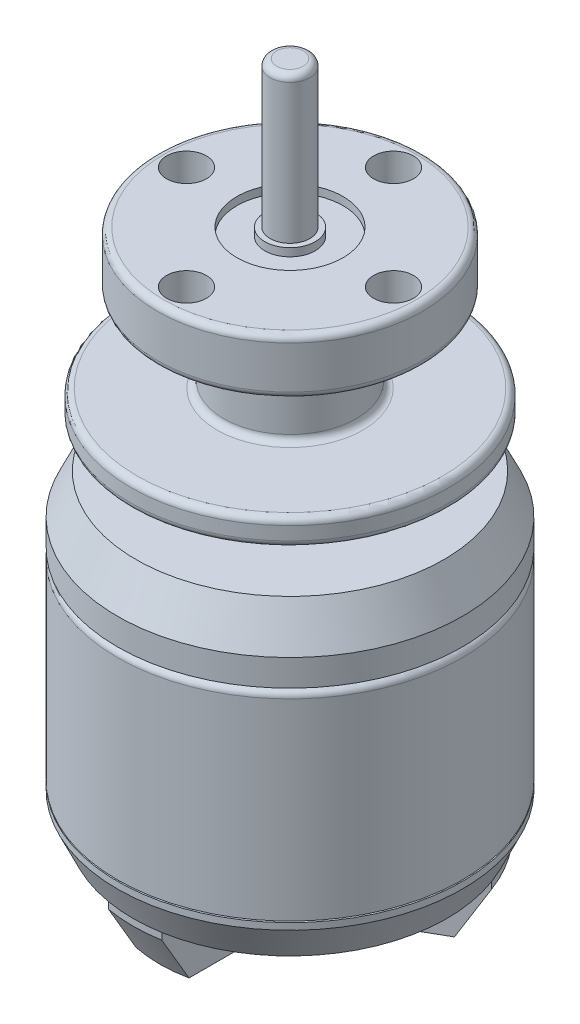
from build123d import *
from OCP.BRepFilletAPI import BRepFilletAPI_MakeChamfer

# Parameters (mm, degrees)
SKETCH1_R            = 13
BOSS_EXTRUDE1_DEPTH  = 15
SKETCH2_R            = 7
BOSS_EXTRUDE2_DEPTH  = 0.2
SKETCH4_R            = 13.000000000000004
BOSS_EXTRUDE3_DEPTH  = 5
SKETCH5_R            = 5
BOSS_EXTRUDE4_DEPTH  = 3.4
SKETCH6_R            = 12
BOSS_EXTRUDE5_DEPTH  = 2
SKETCH7_R            = 5
BOSS_EXTRUDE6_DEPTH  = 6.3
SKETCH8_R            = 10
BOSS_EXTRUDE7_DEPTH  = 4.2
CHAMFER1_SIZE        = 3
CHAMFER1_SIZE2       = 1.3989229744649996
FILLET1_R            = 0.5
SKETCH9_R            = 8.463574214087313
BOSS_EXTRUDE8_DEPTH  = 0.1
BOSS_EXTRUDE9_START  = 3
SKETCH10_R           = 13.000000000000004
BOSS_EXTRUDE9_DEPTH  = 3
CHAMFER2_SIZE        = 2.5
CHAMFER2_SIZE2       = 1.1657691453874992
BOSS_EXTRUDE10_START = 4
BOSS_EXTRUDE10_DEPTH = 4
CHAMFER3_SIZE        = 3.5
CHAMFER3_SIZE2       = 2.0207259421636956
SKETCH13_R           = 10.77059477245057
CUT_EXTRUDE1_DEPTH   = 4
SKETCH14_R           = 4.5
BOSS_EXTRUDE11_DEPTH = 1
FILLET2_R            = 0.7
FILLET3_R            = 2
SKETCH15_R           = 1.5000000000000002
CUT_EXTRUDE2_DEPTH   = 4
CIRPATTERN1_COUNT    = 3
SKETCH16_R           = 1.7
SKETCH16_R_2         = 1.5
CUT_EXTRUDE3_DEPTH   = 2
FILLET4_R            = 0.3
SKETCH17_R           = 4
SKETCH17_R_2         = 1.9
CUT_EXTRUDE4_DEPTH   = 0.6
SKETCH18_R           = 1.5
BOSS_EXTRUDE12_DEPTH = 11
FILLET5_R            = 0.5
SKETCH19_R           = 1.4999999999999998
CUT_EXTRUDE5_DEPTH   = 5
CIRPATTERN2_COUNT    = 4


with BuildPart() as part:
    # Sketch1 → Boss-Extrude1 (new body)
    with BuildSketch(Plane(origin=(0, 0, 0), x_dir=(1, 0, 0), z_dir=(0, 1, 0))):
        with Locations(Location((0, 0, 0), (0, 0, 270))):
            Circle(SKETCH1_R)
    extrude(amount=BOSS_EXTRUDE1_DEPTH)

    # Sketch2 → Boss-Extrude2 (add)
    with BuildSketch(Plane(origin=(0, 15, 0), x_dir=(1, 0, 0), z_dir=(0, 1, 0))):
        with Locations(Location((0, 0, 0), (0, 0, 270))):
            Circle(SKETCH2_R)
    extrude(amount=BOSS_EXTRUDE2_DEPTH)

    # Sketch4 → Boss-Extrude3 (add)
    with BuildSketch(Plane(origin=(0, 15.2, 0), x_dir=(1, 0, 0), z_dir=(0, 1, 0))):
        with Locations(Location((0, 0, 0), (0, 0, 270))):
            Circle(SKETCH4_R)
    extrude(amount=BOSS_EXTRUDE3_DEPTH)

    # Sketch5 → Boss-Extrude4 (add)
    with BuildSketch(Plane(origin=(0, 20.2, 0), x_dir=(1, 0, 0), z_dir=(0, 1, 0))):
        with Locations(Location((0, 0, 0), (0, 0, 270))):
            Circle(SKETCH5_R)
    extrude(amount=BOSS_EXTRUDE4_DEPTH)

    # Sketch6 → Boss-Extrude5 (add)
    with BuildSketch(Plane(origin=(0, 23.599999999999998, 0), x_dir=(1, 0, 0), z_dir=(0, 1, 0))):
        with Locations(Location((0, 0, 0), (0, 0, 270))):
            Circle(SKETCH6_R)
    extrude(amount=BOSS_EXTRUDE5_DEPTH)

    # Sketch7 → Boss-Extrude6 (add)
    with BuildSketch(Plane(origin=(0, 25.599999999999998, 0), x_dir=(1, 0, 0), z_dir=(0, 1, 0))):
        with Locations(Location((0, 0, 0), (0, 0, 270))):
            Circle(SKETCH7_R)
    extrude(amount=BOSS_EXTRUDE6_DEPTH)

    # Sketch8 → Boss-Extrude7 (add)
    with BuildSketch(Plane(origin=(0, 31.9, 0), x_dir=(1, 0, 0), z_dir=(0, 1, 0))):
        with Locations(Location((0, 0, 0), (0, 0, 270))):
            Circle(SKETCH8_R)
    extrude(amount=BOSS_EXTRUDE7_DEPTH)

    # Chamfer1
    chamfer1_edges = [part.edges().sort_by_distance(p)[0] for p in [
        (3.98e-15, 20.2, -13.000000000000004),
    ]]
    chamfer1_side = [part.faces().sort_by_distance(p)[0] for p in [
        (3.98e-15, 17.7, -13.000000000000004),
    ]]
    chamfer(chamfer1_edges, length=CHAMFER1_SIZE, length2=CHAMFER1_SIZE2, reference=chamfer1_side[0])

    # Fillet1
    fillet1_edges = [part.edges().sort_by_distance(p)[0] for p in [
        (1.53e-15, 20.2, -5),
        (1.53e-15, 23.599999999999998, -5),
        (3.67e-15, 23.599999999999998, -12),
        (3.67e-15, 25.599999999999998, -12),
        (1.53e-15, 25.599999999999998, -5),
        (1.53e-15, 31.9, -5),
        (3.06e-15, 31.9, -10),
        (3.06e-15, 36.1, -10),
        (-1.79e-15, 15, -13),
    ]]
    fillet(fillet1_edges, radius=FILLET1_R)

    # Sketch9 → Boss-Extrude8 (add)
    with BuildSketch(Plane.XZ):
        with Locations(Location((0, 0, 0), (0, 0, 270))):
            Circle(SKETCH9_R)
    extrude(amount=BOSS_EXTRUDE8_DEPTH)

    # Sketch10 → Boss-Extrude9 (add)
    with BuildSketch(Plane.XZ.offset(0.1).offset(BOSS_EXTRUDE9_START)):
        with Locations(Location((0, 0, 0), (0, 0, 90))):
            Circle(SKETCH10_R)
    extrude(amount=-BOSS_EXTRUDE9_DEPTH)

    # Chamfer2
    chamfer2_edges = [part.edges().sort_by_distance(p)[0] for p in [
        (-2.39e-15, -3.1, -13.000000000000004),
    ]]
    chamfer2_side = [part.faces().sort_by_distance(p)[0] for p in [
        (-2.39e-15, -1.6, -13.000000000000004),
    ]]
    chamfer(chamfer2_edges, length=CHAMFER2_SIZE, length2=CHAMFER2_SIZE2, reference=chamfer2_side[0])

    # Sketch12 → Boss-Extrude10 (add)
    with BuildSketch(Plane.XZ.offset(3.1).offset(BOSS_EXTRUDE10_START)):
        with BuildLine():
            Line((-4.968626966596926, -0.5592370399090334), (-11.10132491013915, -4.099951848471753))
            ThreePointArc((-11.1013249101391, -4.099951848471809), (-10.713631015383742, -5.026642058717716), (-10.248744788504228, -5.917115021728898))
            ThreePointArc((-10.248744788504228, -5.917115021728898), (-9.710015493984855, -6.764955212478231), (-9.101324910139237, -7.564053463609399))
            Line((-9.101324910139185, -7.56405346360953), (-2.9686269665968643, -4.023338655046755))
            ThreePointArc((-2.96862696659685, -4.023338655046824), (-4.330127018922175, -2.5000000000000315), (-4.968626966596883, -0.5592370399090708))
        make_face()
        with BuildLine():
            Line((-2.0000000000000036, 1.1547005383792586), (-4.968626966596926, -0.5592370399090334))
            ThreePointArc((-4.968626966596883, -0.5592370399090708), (-4.330127018922175, -2.5000000000000315), (-2.96862696659685, -4.023338655046824))
            Line((-2.9686269665968643, -4.023338655046755), (-3.55e-15, -2.3094010767584994))
            Line((-5.33e-15, -2.3094010767585016), (-1.000000000000002, -1.7320508075688765))
            Line((-1.000000000000002, -1.7320508075688765), (4.4e-16, 2.2e-16))
            Line((0, 2.3e-16), (-2, -1e-17))
            Line((-2, -1e-17), (-2, 1.15470053837926))
        make_face()
        with BuildLine():
            Line((-3.55e-15, -2.3094010767584994), (-2.9686269665968643, -4.023338655046755))
            ThreePointArc((-2.96862696659685, -4.023338655046824), (-1.868e-14, -5), (2.96862696659682, -4.023338655046846))
            Line((2.968626966596837, -4.023338655046775), (-5.33e-15, -2.3094010767585016))
        make_face()
        with BuildLine():
            Line((0.9999999999999911, -1.7320508075688847), (-3.55e-15, -2.3094010767584994))
            Line((-5.33e-15, -2.3094010767585016), (2.968626966596837, -4.023338655046775))
            ThreePointArc((2.96862696659682, -4.023338655046846), (4.330127018922203, -2.499999999999983), (4.968626966596899, -0.559237039908927))
            Line((4.968626966596811, -0.5592370399090061), (2.0000000000000027, 1.1547005383792481))
            Line((2.000000000000002, 1.1547005383792481), (2.0000000000000027, 4.8e-16))
            Line((2.0000000000000027, 4.8e-16), (0, 2.3e-16))
            Line((2.2e-16, -2.2e-16), (0.9999999999999907, -1.7320508075688847))
        make_face()
        with BuildLine():
            Line((2.968626966596837, -4.023338655046775), (9.10132491013913, -7.564053463609591))
            ThreePointArc((9.101324910139173, -7.564053463609475), (9.710015458843332, -6.76495526291829), (10.248744727029683, -5.917115128205941))
            ThreePointArc((10.248744727029683, -5.917115128205941), (10.713630989272133, -5.026642114371199), (11.101324910139066, -4.0999518484719015))
            Line((11.101324910139121, -4.099951848471832), (4.968626966596811, -0.5592370399090061))
            ThreePointArc((4.968626966596899, -0.559237039908927), (4.330127018922203, -2.499999999999983), (2.96862696659682, -4.023338655046846))
        make_face()
        Polygon((-1.000000000000002, -1.7320508075688765), (-5.33e-15, -2.3094010767585016), (0.9999999999999911, -1.7320508075688847), (2.2e-16, -2.2e-16), align=None)
        Polygon((1.000000000000002, 1.7320508075688756), (4.4e-16, 2.2e-16), (2.0000000000000027, 4.8e-16), (2.000000000000002, 1.1547005383792481), align=None)
        with BuildLine():
            ThreePointArc((5, 0), (4.183300132670404, 2.738612787525792), (2.0000000000000853, 4.5825756949558025))
            Line((2.0000000000000018, 4.582575694955776), (2.000000000000002, 1.1547005383792481))
            Line((2.0000000000000027, 1.1547005383792481), (4.968626966596811, -0.5592370399090061))
            ThreePointArc((4.968626966596899, -0.559237039908927), (4.992150580310278, -0.28005817879104034), (5, -1.22e-15))
        make_face()
        with BuildLine():
            Line((-2, 4.582575694955866), (-2, 1.15470053837926))
            Line((-2.0000000000000036, 1.1547005383792586), (-0.9999999999999911, 1.7320508075688839))
            Line((-0.9999999999999902, 1.7320508075688843), (2.2e-16, -2.2e-16))
            Line((4.4e-16, 2.2e-16), (1.000000000000002, 1.7320508075688756))
            Line((1.000000000000002, 1.7320508075688756), (2.0000000000000027, 1.1547005383792481))
            Line((2.000000000000002, 1.1547005383792481), (2.0000000000000018, 4.582575694955776))
            ThreePointArc((2.0000000000000853, 4.5825756949558025), (6.47e-14, 5), (-1.9999999999999662, 4.582575694955855))
        make_face()
        with BuildLine():
            ThreePointArc((-1.9999999999999662, 4.582575694955855), (-4.330127018922191, 2.500000000000004), (-4.968626966596883, -0.5592370399090708))
            Line((-4.968626966596926, -0.5592370399090334), (-2.0000000000000036, 1.1547005383792586))
            Line((-2, 1.15470053837926), (-2, 4.582575694955866))
        make_face()
        with BuildLine():
            ThreePointArc((5.853e-14, 11.834230854612493), (-1.0036155557942605, 11.791597675312286), (-1.9999999999997802, 11.664005312081404))
            Line((-2, 11.66400531208144), (-2, 4.582575694955866))
            ThreePointArc((-1.9999999999999662, 4.582575694955855), (6.47e-14, 5), (2.0000000000000853, 4.5825756949558025))
            Line((2.0000000000000018, 4.582575694955776), (2, 11.664005312081269))
            ThreePointArc((2.0000000000002918, 11.664005312081317), (1.0036155557945787, 11.791597675312259), (5.853e-14, 11.834230854612493))
        make_face()
        Polygon((-0.9999999999999911, 1.7320508075688839), (-2.0000000000000036, 1.1547005383792586), (-2, -1e-17), (0, 2.3e-16), align=None)
    extrude(amount=-BOSS_EXTRUDE10_DEPTH)

    # Chamfer3: one chamfer whose edges measure the first distance from different faces: ONE call of the kernel's chamfer builder (chamfer() names one face for all edges)
    chamfer3_edges_1 = [part.edges().sort_by_distance(p)[0] for p in [
        (10.248744554344045, -7.1, -5.917115427306248),
    ]]
    chamfer3_side_1 = [part.faces().sort_by_distance(p)[0] for p in [
        (10.248744554344047, -5.1, -5.917115427306248),
    ]]
    chamfer3_edges_2 = [part.edges().sort_by_distance(p)[0] for p in [
        (1.3683e-13, -7.1, 11.834230854612489),
    ]]
    chamfer3_side_2 = [part.faces().sort_by_distance(p)[0] for p in [
        (2.936e-13, -5.1, 11.834230854612489),
    ]]
    chamfer3_edges_3 = [part.edges().sort_by_distance(p)[0] for p in [
        (-10.24874455434409, -7.1, -5.917115427306171),
    ]]
    chamfer3_side_3 = [part.faces().sort_by_distance(p)[0] for p in [
        (-10.24874455434409, -5.1, -5.9171154273061735),
    ]]
    chamfer3 = BRepFilletAPI_MakeChamfer(part.part.solid().wrapped)
    for e in chamfer3_edges_1:
        chamfer3.Add(CHAMFER3_SIZE, CHAMFER3_SIZE2, e.wrapped, chamfer3_side_1[0].wrapped)  # the first distance lies on this face
    for e in chamfer3_edges_2:
        chamfer3.Add(CHAMFER3_SIZE, CHAMFER3_SIZE2, e.wrapped, chamfer3_side_2[0].wrapped)  # the first distance lies on this face
    for e in chamfer3_edges_3:
        chamfer3.Add(CHAMFER3_SIZE, CHAMFER3_SIZE2, e.wrapped, chamfer3_side_3[0].wrapped)  # the first distance lies on this face
    add(Compound.cast(chamfer3.Shape()), mode=Mode.REPLACE)

    # Sketch13 → Cut-Extrude1 (cut)
    with BuildSketch(Plane.XZ.offset(3.1)):
        with Locations(Location((0, 0, 0), (0, 0, 270))):
            Circle(SKETCH13_R)
    extrude(amount=-CUT_EXTRUDE1_DEPTH, mode=Mode.SUBTRACT)


with BuildPart() as cut_extrude1_piece_1:
    # of the separate pieces the step leaves, piece 1, a body of its own (cut_extrude1_pieces)
    add(part.part.solids().sort_by_distance((0, 0, 13))[0])

    # Sketch17 → Cut-Extrude4 (cut)
    with BuildSketch(Plane(origin=(0, 36.1, 0), x_dir=(1, 0, 0), z_dir=(0, 1, 0))):
        with Locations(Location((0, 0, 0), (0, 0, 270))):
            Circle(SKETCH17_R)
        with Locations(Location((0, 0, 0), (0, 0, 270))):
            Circle(SKETCH17_R_2, mode=Mode.SUBTRACT)
    extrude(amount=-CUT_EXTRUDE4_DEPTH, mode=Mode.SUBTRACT)

    # Sketch18 → Boss-Extrude12 (add)
    with BuildSketch(Plane(origin=(0, 36.1, 0), x_dir=(1, 0, 0), z_dir=(0, 1, 0))):
        with Locations(Location((0, 0, 0), (0, 0, 270))):
            Circle(SKETCH18_R)
    extrude(amount=BOSS_EXTRUDE12_DEPTH)

    # Fillet5
    fillet5_edges = [cut_extrude1_piece_1.edges().sort_by_distance(p)[0] for p in [
        (4.6e-16, 47.1, -1.5),
    ]]
    fillet(fillet5_edges, radius=FILLET5_R)

    # Sketch19 → Cut-Extrude5 (cut)
    with BuildSketch(Plane(origin=(0, 36.1, 0), x_dir=(1, 0, 0), z_dir=(0, 1, 0))):
        with Locations(Location((0, 7.8, 0), (0, 0, 270))):
            Circle(SKETCH19_R)
    cut_extrude5 = extrude(amount=-CUT_EXTRUDE5_DEPTH, mode=Mode.SUBTRACT)

    # CirPattern2: Cut-Extrude5 ×4 about axis
    cirpattern2_axis = Axis((-1.362e-14, 0, 0), (0, 1, 0))
    for i in range(1, CIRPATTERN2_COUNT):
        add(cut_extrude5.rotate(cirpattern2_axis, i * 360 / CIRPATTERN2_COUNT), mode=Mode.SUBTRACT)


with BuildPart() as cut_extrude1_piece_2:
    # of the separate pieces the step leaves, piece 2, a body of its own (cut_extrude1_pieces)
    add(part.part.solids().sort_by_distance((2, -3.6, 11.664005312))[0])

    # Sketch14 → Boss-Extrude11 (add)
    with BuildSketch(Plane.XZ.offset(7.1000000000000005)):
        with Locations(Location((0, 0, 0), (0, 0, 270))):
            Circle(SKETCH14_R)
    extrude(amount=BOSS_EXTRUDE11_DEPTH)

    # Fillet2
    fillet2_edges = [cut_extrude1_piece_2.edges().sort_by_distance(p)[0] for p in [
        (1.38e-15, -8.100000000000001, 4.5),
    ]]
    fillet(fillet2_edges, radius=FILLET2_R)

    # Fillet3
    fillet3_edges = [cut_extrude1_piece_2.edges().sort_by_distance(p)[0] for p in [
        (-2.968626966596857, -5.1, -4.023338655046789),
        (2.968626966596829, -5.1, -4.02333865504681),
        (4.9686269665968545, -5.1, -0.5592370399089666),
        (2.0000000000000435, -5.1, 4.582575694955789),
        (-1.9999999999999831, -5.1, 4.58257569495586),
        (-4.968626966596904, -5.1, -0.5592370399090523),
    ]]
    fillet(fillet3_edges, radius=FILLET3_R)

    # Sketch15 → Cut-Extrude2 (cut)
    with BuildSketch(Plane.XZ.offset(7.1000000000000005)):
        with Locations(Location((0, 6.5, 0), (0, 0, 270))):
            Circle(SKETCH15_R)
    cut_extrude2 = extrude(amount=-CUT_EXTRUDE2_DEPTH, mode=Mode.SUBTRACT)

    # CirPattern1: Cut-Extrude2 ×3 about axis
    cirpattern1_axis = Axis((-9e-17, 0, -3.4e-16), (0, 1, 0))
    for i in range(1, CIRPATTERN1_COUNT):
        add(cut_extrude2.rotate(cirpattern1_axis, i * 360 / CIRPATTERN1_COUNT), mode=Mode.SUBTRACT)

    # Sketch16 → Cut-Extrude3 (cut)
    with BuildSketch(Plane.XZ.offset(8.1)):
        with Locations(Location((0, 0, 0), (0, 0, 270))):
            Circle(SKETCH16_R)
        with Locations(Location((0, 0, 0), (0, 0, 270))):
            Circle(SKETCH16_R_2, mode=Mode.SUBTRACT)
    extrude(amount=-CUT_EXTRUDE3_DEPTH, mode=Mode.SUBTRACT)

    # Fillet4
    fillet4_edges = [cut_extrude1_piece_2.edges().sort_by_distance(p)[0] for p in [
        (4.6e-16, -8.1, 1.5),
    ]]
    fillet(fillet4_edges, radius=FILLET4_R)


solid = Compound([cut_extrude1_piece_1.part, cut_extrude1_piece_2.part])
